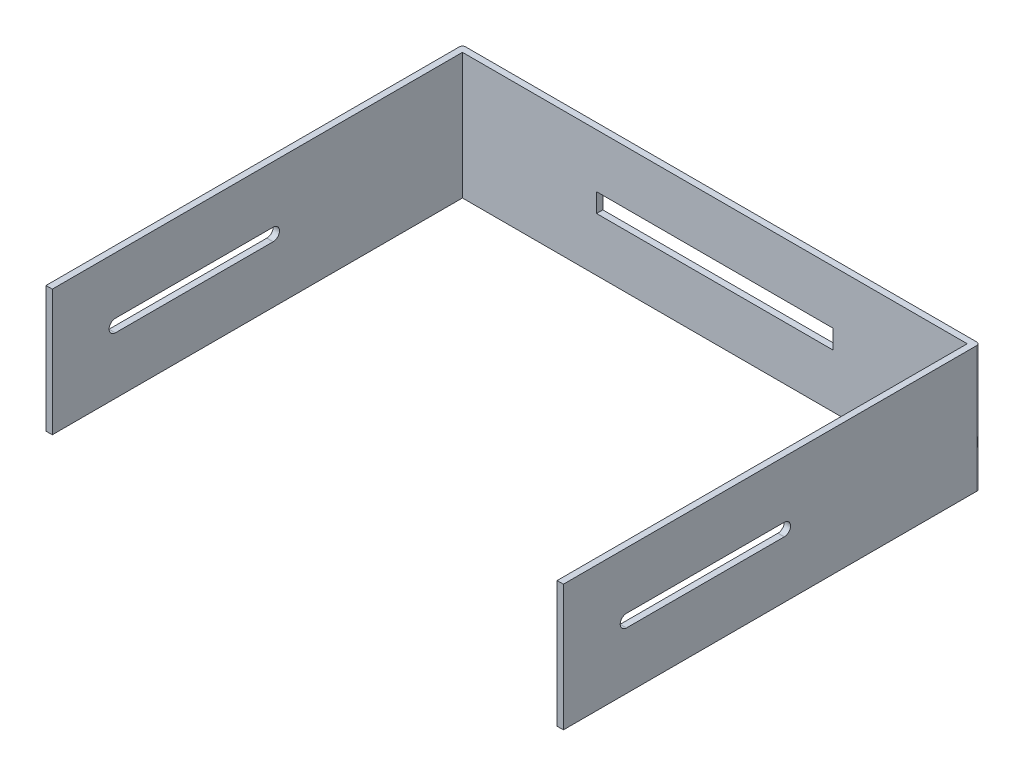
from build123d import *

# Parameters (mm, degrees)
ESQUISSE1_W             = 164
ESQUISSE1_H             = 40
BOSS_EXTRU_1_DEPTH      = 2
ESQUISSE2_W             = 2
ESQUISSE2_H             = 40
BOSS_EXTRU_2_DEPTH      = 130
ESQUISSE3_W             = 2
ESQUISSE3_H             = 40
BOSS_EXTRU_3_DEPTH      = 130
ESQUISSE4_R             = 2
ENL_V_MAT_EXTRU_1_DEPTH = 165
CONG_1_R                = 1
CONG_2_R                = 1
ESQUISSE5_W             = 75
ESQUISSE5_H             = 6
ENL_V_MAT_EXTRU_2_DEPTH = 130
ENL_V_MAT_EXTRU_3_DEPTH = 165


with BuildPart() as part:
    # Esquisse1 → Boss.-Extru.1 (new body)
    with BuildSketch(Plane.XY):
        with Locations((82, -20)):
            Rectangle(ESQUISSE1_W, ESQUISSE1_H)
    extrude(amount=BOSS_EXTRU_1_DEPTH)

    # Esquisse2 → Boss.-Extru.2 (add)
    with BuildSketch(Plane.XY.offset(2)):
        with Locations((1, -20)):
            Rectangle(ESQUISSE2_W, ESQUISSE2_H)
    extrude(amount=BOSS_EXTRU_2_DEPTH)

    # Esquisse3 → Boss.-Extru.3 (add)
    with BuildSketch(Plane.XY.offset(2)):
        with Locations((163, -20)):
            Rectangle(ESQUISSE3_W, ESQUISSE3_H)
    extrude(amount=BOSS_EXTRU_3_DEPTH)

    # Esquisse4 → Enlèv. mat.-Extru.1 (cut, through all)
    with BuildSketch(Plane.ZY):
        with Locations((112, -20)):
            Circle(ESQUISSE4_R)
    extrude(amount=-ENL_V_MAT_EXTRU_1_DEPTH, mode=Mode.SUBTRACT)

    # Congé1
    cong_1_edges = [part.edges().sort_by_distance(p)[0] for p in [
        (0, -20, 0),
    ]]
    fillet(cong_1_edges, radius=CONG_1_R)

    # Congé2
    cong_2_edges = [part.edges().sort_by_distance(p)[0] for p in [
        (164, -20, 0),
    ]]
    fillet(cong_2_edges, radius=CONG_2_R)

    # Esquisse5 → Enlèv. mat.-Extru.2 (cut)
    with BuildSketch(Plane.XY.offset(2)):
        with Locations((82, -20)):
            Rectangle(ESQUISSE5_W, ESQUISSE5_H)
    extrude(amount=-ENL_V_MAT_EXTRU_2_DEPTH, mode=Mode.SUBTRACT)

    # Esquisse6 → Enlèv. mat.-Extru.3 (cut, through all)
    with BuildSketch(Plane.ZY):
        with BuildLine():
            Line((62, -18), (112, -18))
            ThreePointArc((112, -18), (114, -20), (112, -22))
            Line((112, -22), (62, -22))
            ThreePointArc((62, -22), (60, -20), (62, -18))
        make_face()
    extrude(amount=-ENL_V_MAT_EXTRU_3_DEPTH, mode=Mode.SUBTRACT)


solid = part.part
